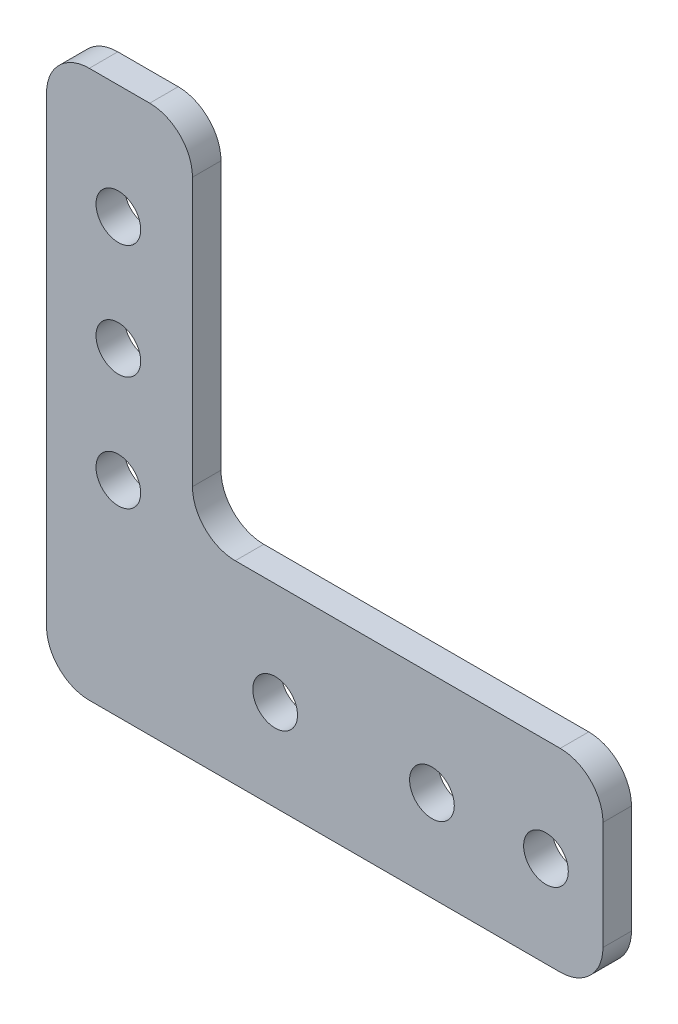
from build123d import *

# Parameters (mm, degrees)
SKETCH1_R           = 2.4892
BOSS_EXTRUDE1_DEPTH = 3.175
FILLET1_R           = 4.7625


with BuildPart() as part:
    # Sketch1 → Boss-Extrude1 (new body)
    with BuildSketch(Plane.XY):
        Polygon((-27.051, 31.75), (-27.051, -29.21), (34.925, -29.21), (34.925, -7.62), (-10.795, -7.62), (-10.795, 31.75), align=None)
        with Locations((-19.05, -19.05)):
            Circle(SKETCH1_R, mode=Mode.SUBTRACT)
        with Locations((-1.5875, -19.05)):
            Circle(SKETCH1_R, mode=Mode.SUBTRACT)
        with Locations((-19.05, -6.35)):
            Circle(SKETCH1_R, mode=Mode.SUBTRACT)
        with Locations((15.875, -19.05)):
            Circle(SKETCH1_R, mode=Mode.SUBTRACT)
        with Locations((28.575, -19.05)):
            Circle(SKETCH1_R, mode=Mode.SUBTRACT)
        with Locations((-19.05, 6.35)):
            Circle(SKETCH1_R, mode=Mode.SUBTRACT)
        with Locations((-19.05, 19.05)):
            Circle(SKETCH1_R, mode=Mode.SUBTRACT)
        with Locations((-19.05, -19.05)):
            Circle(SKETCH1_R)
    extrude(amount=BOSS_EXTRUDE1_DEPTH)

    # Fillet1
    fillet1_edges = [part.edges().sort_by_distance(p)[0] for p in [
        (-27.051, 31.75, 1.5875),
        (-10.795, 31.75, 1.5875),
        (-10.795, -7.62, 1.5875),
        (34.925, -7.62, 1.5875),
        (34.925, -29.21, 1.5875),
        (-27.051, -29.21, 1.5875),
    ]]
    fillet(fillet1_edges, radius=FILLET1_R)


solid = part.part
